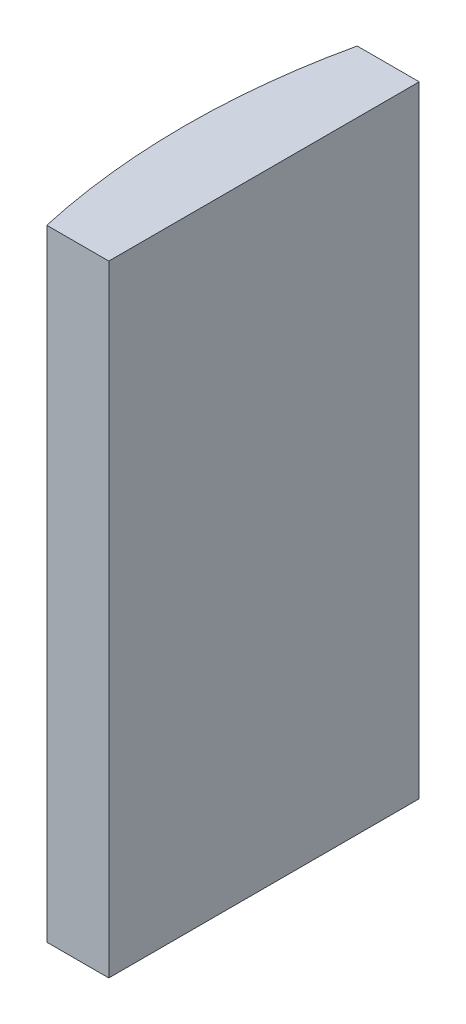
from build123d import *

# Parameters (mm, degrees)
EXTRUDE_1_DEPTH = 20


with BuildPart() as part:
    # 草图1 → 凸台-拉伸1 (new body)
    with BuildSketch(Plane(origin=(0, 0, 0), x_dir=(1, 0, 0), z_dir=(0, 1, 0))):
        with BuildLine():
            Line((-18.012772775, 5), (-16.014795665, 5))
            Line((-16.014795665, 5), (-16.014795665, -5))
            Line((-16.014795665, -5), (-18.012772775, -5))
            ThreePointArc((-18.012772775, -5), (-18.564795665, 0), (-18.012772775, 5))
        make_face()
    extrude(amount=EXTRUDE_1_DEPTH)


solid = part.part
